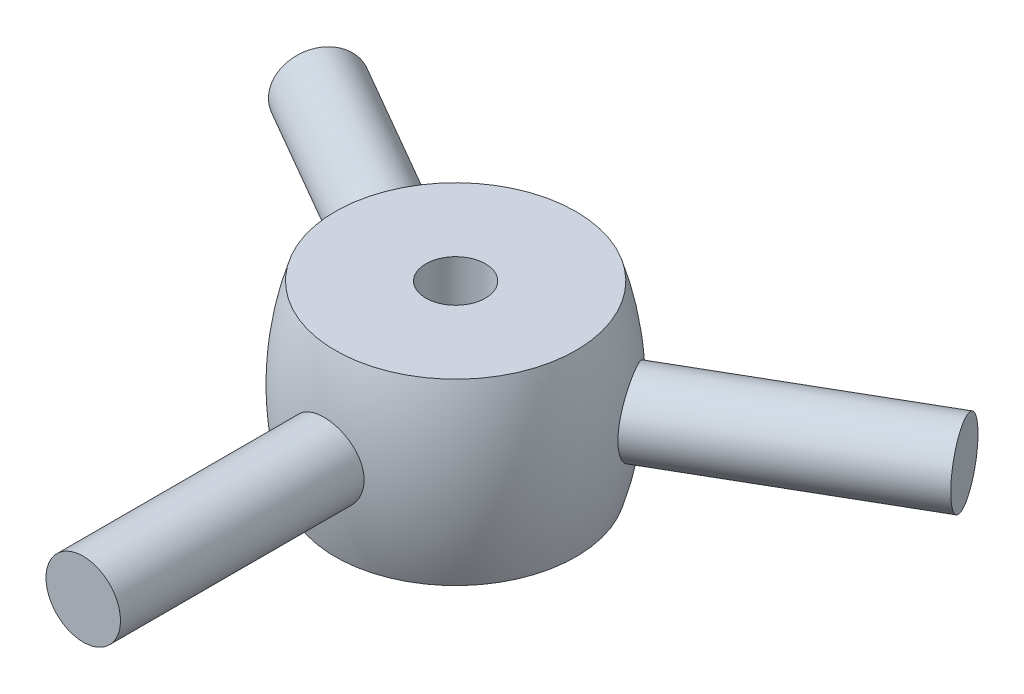
from build123d import *

# Parameters (mm, degrees)
ESQUISSE3_R                  = 1.25
BOSS_EXTRU_1_DEPTH           = 12.5
R_P_TITION_CIRCULAIRE1_COUNT = 3
ESQUISSE2_R                  = 1
ENL_V_MAT_EXTRU_2_DEPTH      = 7.0000001


with BuildPart() as part:
    # Esquisse1 → Base-Révolution (revolve)
    with BuildSketch(Plane.XY):
        with BuildLine():
            Line((0, 3), (4.039392014, 3))
            ThreePointArc((4.039392014, 3), (4.5, 0), (4.039392014, -3))
            Line((4.039392014, -3), (0, -3))
            Line((0, -3), (0, 3))
        make_face()
    revolve(axis=Axis((0, -3, 0), (0, 1, 0)))

    # Esquisse3 → Boss.-Extru.1 (add)
    with BuildSketch(Plane.XY):
        Circle(ESQUISSE3_R)
    boss_extru_1 = extrude(amount=BOSS_EXTRU_1_DEPTH)

    # Répétition circulaire1: Boss.-Extru.1 ×3 about axis
    r_p_tition_circulaire1_axis = Axis((0, -3, 0), (0, 1, 0))
    for i in range(1, R_P_TITION_CIRCULAIRE1_COUNT):
        add(boss_extru_1.rotate(r_p_tition_circulaire1_axis, i * 360 / R_P_TITION_CIRCULAIRE1_COUNT))

    # Esquisse2 → Enlèv. mat.-Extru.2 (cut, through all)
    with BuildSketch(Plane.XZ.offset(3)):
        Circle(ESQUISSE2_R)
    extrude(amount=-ENL_V_MAT_EXTRU_2_DEPTH, mode=Mode.SUBTRACT)


solid = part.part
